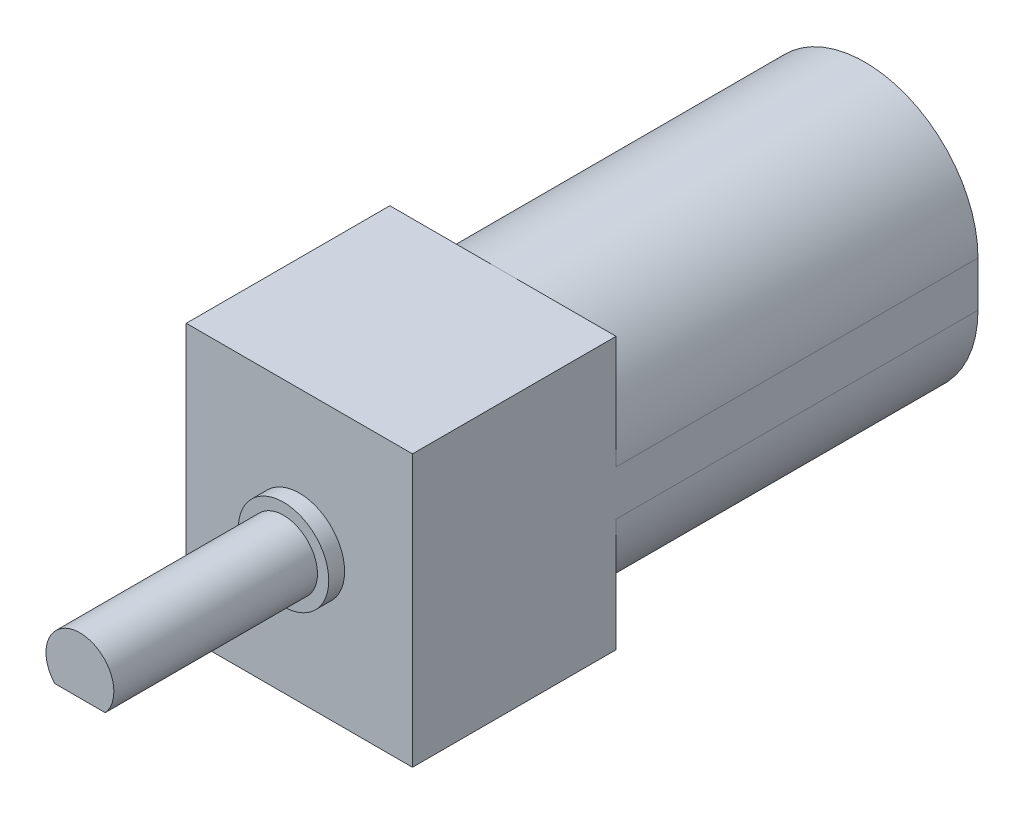
from build123d import *

# Parameters (mm, degrees)
BOSS_EXTRUDE1_DEPTH = 16
SKETCH2_R           = 2.5
BOSS_EXTRUDE2_DEPTH = 1.3
SKETCH3_W           = 10
SKETCH3_H           = 12
BOSS_EXTRUDE3_DEPTH = 9
SKETCH4_R           = 2
BOSS_EXTRUDE4_DEPTH = 0.7
SKETCH5_R           = 1.5
BOSS_EXTRUDE5_DEPTH = 9
SKETCH6_W           = 5.348549536
SKETCH6_H           = 1.415696151
CUT_EXTRUDE1_DEPTH  = 8.9


with BuildPart() as part:
    # Sketch1 → Boss-Extrude1 (new body)
    with BuildSketch(Plane.XY):
        with BuildLine():
            Line((-5, -1), (-5, 1))
            ThreePointArc((-5, 1), (0, 6), (5, 1))
            Line((5, 1), (5, -1))
            ThreePointArc((5, -1), (0, -6), (-5, -1))
        make_face()
    extrude(amount=BOSS_EXTRUDE1_DEPTH)

    # Sketch2 → Boss-Extrude2 (add)
    with BuildSketch(Plane(origin=(0, 0, 0), x_dir=(-1, 0, 0), z_dir=(0, 0, -1))):
        Circle(SKETCH2_R)
    extrude(amount=BOSS_EXTRUDE2_DEPTH)

    # Sketch3 → Boss-Extrude3 (add)
    with BuildSketch(Plane.XY.offset(16)):
        Rectangle(SKETCH3_W, SKETCH3_H)
    extrude(amount=BOSS_EXTRUDE3_DEPTH)

    # Sketch4 → Boss-Extrude4 (add)
    with BuildSketch(Plane.XY.offset(25)):
        Circle(SKETCH4_R)
    extrude(amount=BOSS_EXTRUDE4_DEPTH)

    # Sketch5 → Boss-Extrude5 (add)
    with BuildSketch(Plane.XY.offset(25.7)):
        Circle(SKETCH5_R)
    extrude(amount=BOSS_EXTRUDE5_DEPTH)

    # Sketch6 → Cut-Extrude1 (cut)
    with BuildSketch(Plane.XY.offset(34.7)):
        with Locations((0, -1.707848076)):
            Rectangle(SKETCH6_W, SKETCH6_H)
    extrude(amount=-CUT_EXTRUDE1_DEPTH, mode=Mode.SUBTRACT)


solid = part.part
